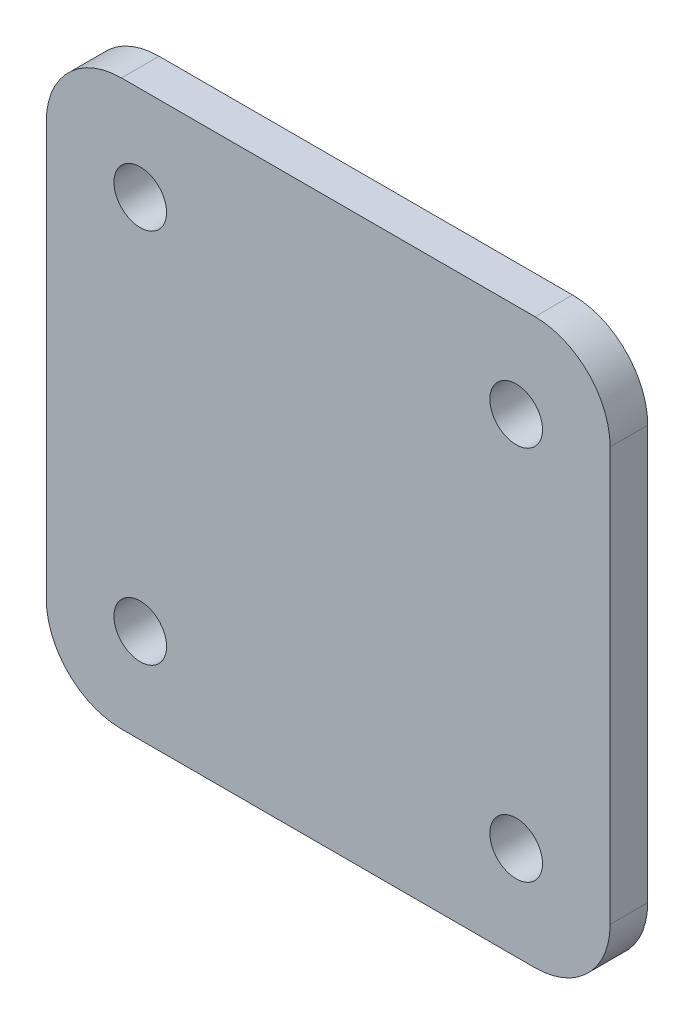
from build123d import *

# Parameters (mm, degrees)
SKETCH1_W                = 75
SKETCH1_H                = 75
BOSS_EXTRUDE1_DEPTH      = 5
F_7_0_7_DIAMETER_HOLE1_D = 7
FILLET1_R                = 10


with BuildPart() as part:
    # Sketch1 → Boss-Extrude1 (new body)
    with BuildSketch(Plane.XY):
        Rectangle(SKETCH1_W, SKETCH1_H)
    extrude(amount=BOSS_EXTRUDE1_DEPTH)

    # Ø7.0 (7) Diameter Hole1 (through all)
    with Locations(Plane.XY.offset(5)):
        with Locations((-25, 25), (-25, -25), (25, -25), (25, 25)):
            Hole(F_7_0_7_DIAMETER_HOLE1_D / 2)

    # Fillet1
    fillet1_edges = [part.edges().sort_by_distance(p)[0] for p in [
        (-37.5, 37.5, 2.5),
        (37.5, 37.5, 2.5),
        (37.5, -37.5, 2.5),
        (-37.5, -37.5, 2.5),
    ]]
    fillet(fillet1_edges, radius=FILLET1_R)


solid = part.part
